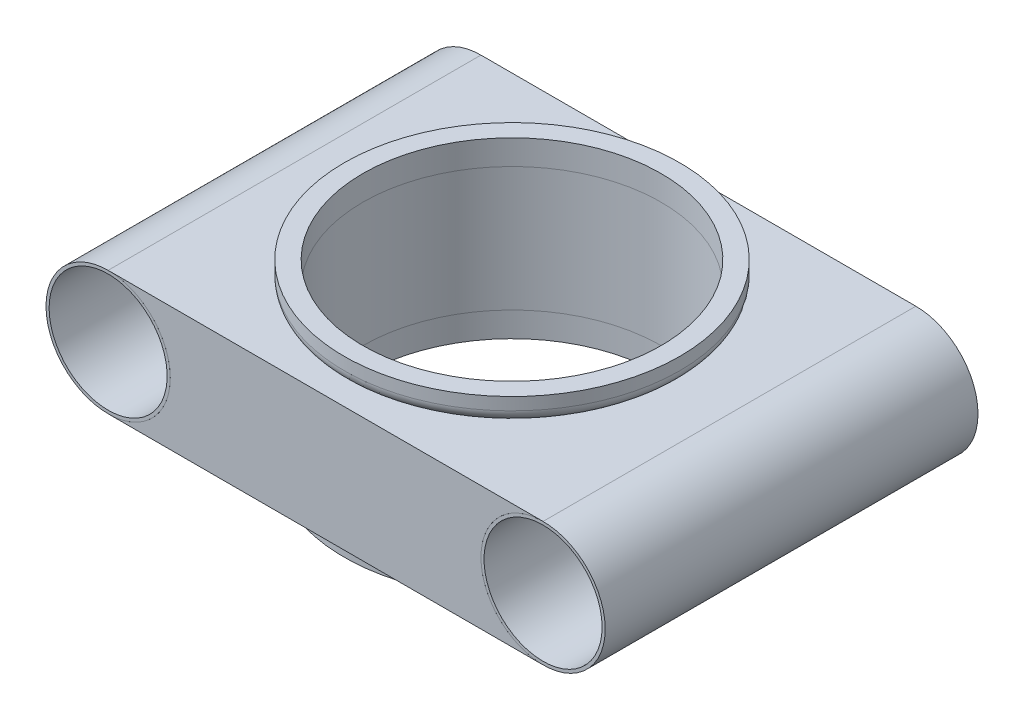
from build123d import *

# Parameters (mm, degrees)
SKETCH1_R                  = 5
SKETCH1_R_2                = 4.75
STRUCTURAL_MEMBER1_DEPTH   = 30
SKETCH1_ON_SEGMENT_2_R     = 5
SKETCH1_ON_SEGMENT_2_R_2   = 4.75
STRUCTURAL_MEMBER1_2_DEPTH = 30
BOSS_EXTRUDE2_DEPTH        = 15
SKETCH21_R                 = 12
CUT_EXTRUDE6_DEPTH         = 10
SKETCH22_R                 = 13.5
SKETCH22_R_2               = 12
BOSS_EXTRUDE3_DEPTH        = 2
FILLET2_R                  = 1


with BuildPart() as part:
    # Sketch1 → Structural Member1 (new body)
    with BuildSketch(Plane(origin=(-17.5, 0, -15), x_dir=(1, 0, 0), z_dir=(0, 0, 1))):
        Circle(SKETCH1_R)
        Circle(SKETCH1_R_2, mode=Mode.SUBTRACT)
    extrude(amount=STRUCTURAL_MEMBER1_DEPTH)


with BuildPart() as body_2:
    # Sketch1 on segment 2 (carried to segment 2) → Structural Member1 2 (new body)
    with BuildSketch(Plane(origin=(17.5, 0, -15), x_dir=(1, 0, 0), z_dir=(0, 0, 1))):
        Circle(SKETCH1_ON_SEGMENT_2_R)
        Circle(SKETCH1_ON_SEGMENT_2_R_2, mode=Mode.SUBTRACT)
    extrude(amount=STRUCTURAL_MEMBER1_2_DEPTH)


with BuildPart() as body_3:
    # Sketch4 → Boss-Extrude2 (new, symmetric)
    with BuildSketch(Plane.XY):
        with BuildLine():
            Line((17.5, 5), (-17.5, 5))
            ThreePointArc((-17.5, 5), (-13.964466094, 3.535533906), (-12.5, 0))
            ThreePointArc((-12.5, 0), (-13.964466094, -3.535533906), (-17.5, -5))
            Line((-17.5, -5), (17.5, -5))
            ThreePointArc((17.5, -5), (12.5, 0), (17.5, 5))
        make_face()
    extrude(amount=BOSS_EXTRUDE2_DEPTH, both=True)

    # Sketch21 → Cut-Extrude6 (cut, symmetric)
    with BuildSketch(Plane(origin=(0, 5, 0), x_dir=(1, 0, 0), z_dir=(0, 1, 0))):
        with Locations(Location((0, 0, 0), (0, 0, 180))):
            Circle(SKETCH21_R)
    extrude(amount=CUT_EXTRUDE6_DEPTH, both=True, mode=Mode.SUBTRACT)


with BuildPart() as body_4:
    # Sketch22 → Boss-Extrude3 (new body)
    with BuildSketch(Plane(origin=(0, 5, 0), x_dir=(1, 0, 0), z_dir=(0, 1, 0))):
        with Locations(Location((0, 0, 0), (0, 0, 180))):
            Circle(SKETCH22_R)
        with Locations(Location((0, 0, 0), (0, 0, 180))):
            Circle(SKETCH22_R_2, mode=Mode.SUBTRACT)
    extrude(amount=BOSS_EXTRUDE3_DEPTH)

    # Fillet2
    fillet2_edges = [body_4.edges().sort_by_distance(p)[0] for p in [
        (13.5, 5, 0),
    ]]
    fillet(fillet2_edges, radius=FILLET2_R)


with BuildPart() as body_5:
    # Mirror1: mirrored copy
    add(body_4.part.mirror(Plane.ZX))


solid = Compound([part.part, body_2.part, body_3.part, body_4.part, body_5.part])
